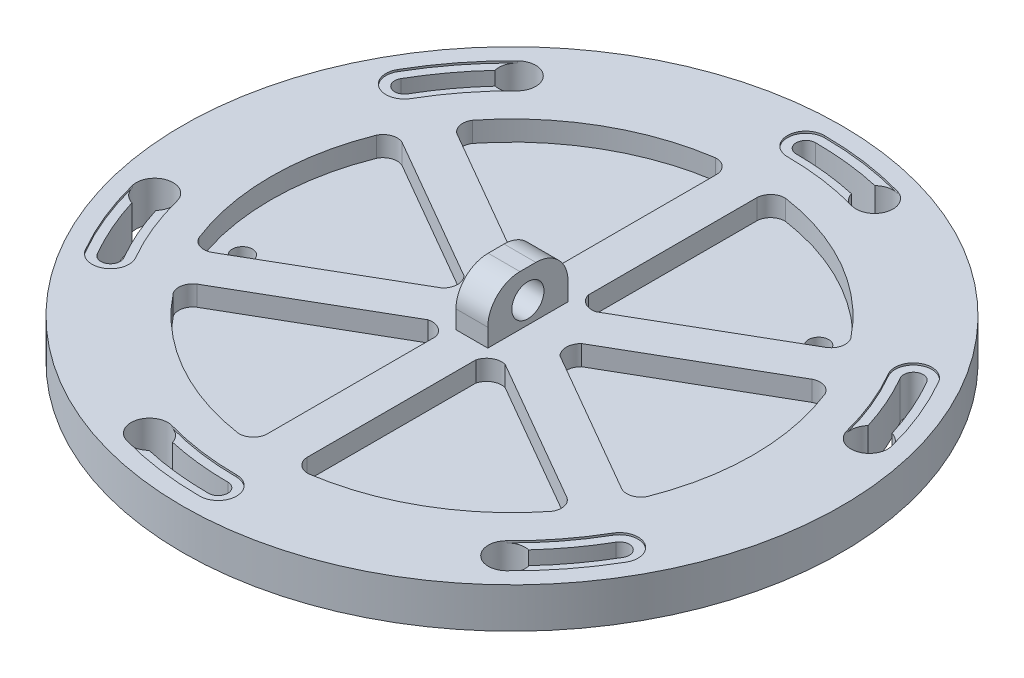
from build123d import *

# Parameters (mm, degrees)
SKETCH1_R           = 82
BOSS_EXTRUDE1_DEPTH = 10
BOSS_EXTRUDE3_DEPTH = 9.525
CIRPATTERN1_COUNT   = 6
CUT_EXTRUDE1_DEPTH  = 5
SKETCH3_R           = 2.5
CUT_EXTRUDE2_DEPTH  = 5
SKETCH3_3_R         = 2.5
CUT_EXTRUDE3_DEPTH  = 5
SKETCH5_W           = 7.911182114
SKETCH5_H           = 19.959178222
BOSS_EXTRUDE5_DEPTH = 12.5
FILLET2_R           = 8
SKETCH7_R           = 4
CUT_EXTRUDE4_DEPTH  = 8.5


with BuildPart() as part:
    # Sketch1 → Boss-Extrude1 (new body)
    with BuildSketch(Plane(origin=(0, 0, 0), x_dir=(1, 0, 0), z_dir=(0, 1, 0))):
        Circle(SKETCH1_R)
        with BuildLine():
            ThreePointArc((0, -68.539794907), (4.585205093, -73.125), (0, -77.710205093))
            ThreePointArc((0, -77.710205093), (-10.627709007, -76.980047914), (-21.05570427, -74.803297343))
            ThreePointArc((-21.05570427, -74.803297343), (-24.227021824, -69.147242492), (-18.570966974, -65.975924939))
            ThreePointArc((-18.570966974, -65.975924939), (-9.373556469, -67.895801969), (0, -68.539794907))
        make_face(mode=Mode.SUBTRACT)
        with BuildLine():
            ThreePointArc((-59.357203559, -34.269897453), (-61.035505105, -40.533404092), (-67.299011744, -38.855102547))
            ThreePointArc((-67.299011744, -38.855102547), (-71.980531582, -29.286157973), (-75.309407921, -19.166873879))
            ThreePointArc((-75.309407921, -19.166873879), (-71.996779512, -13.592404889), (-66.422310522, -16.905033297))
            ThreePointArc((-66.422310522, -16.905033297), (-63.48626755, -25.830162958), (-59.357203559, -34.269897453))
        make_face(mode=Mode.SUBTRACT)
        with BuildLine():
            ThreePointArc((59.357203559, -34.269897453), (65.620710198, -32.591595908), (67.299011744, -38.855102547))
            ThreePointArc((67.299011744, -38.855102547), (61.352822575, -47.693889942), (54.25370365, -55.636423464))
            ThreePointArc((54.25370365, -55.636423464), (47.769757688, -55.554837604), (47.851343548, -49.070891641))
            ThreePointArc((47.851343548, -49.070891641), (54.112711081, -42.065639011), (59.357203559, -34.269897453))
        make_face(mode=Mode.SUBTRACT)
        with BuildLine():
            ThreePointArc((-59.357203559, 34.269897453), (-65.620710198, 32.591595908), (-67.299011744, 38.855102547))
            ThreePointArc((-67.299011744, 38.855102547), (-61.352822575, 47.693889942), (-54.25370365, 55.636423464))
            ThreePointArc((-54.25370365, 55.636423464), (-47.769757688, 55.554837604), (-47.851343548, 49.070891641))
            ThreePointArc((-47.851343548, 49.070891641), (-54.112711081, 42.065639011), (-59.357203559, 34.269897453))
        make_face(mode=Mode.SUBTRACT)
        with BuildLine():
            ThreePointArc((59.357203559, 34.269897453), (61.035505105, 40.533404092), (67.299011744, 38.855102547))
            ThreePointArc((67.299011744, 38.855102547), (71.980531582, 29.286157973), (75.309407921, 19.166873879))
            ThreePointArc((75.309407921, 19.166873879), (71.996779512, 13.592404889), (66.422310522, 16.905033297))
            ThreePointArc((66.422310522, 16.905033297), (63.48626755, 25.830162958), (59.357203559, 34.269897453))
        make_face(mode=Mode.SUBTRACT)
        with BuildLine():
            ThreePointArc((0, 68.539794907), (-4.585205093, 73.125), (0, 77.710205093))
            ThreePointArc((0, 77.710205093), (10.627709007, 76.980047914), (21.05570427, 74.803297343))
            ThreePointArc((21.05570427, 74.803297343), (24.227021824, 69.147242492), (18.570966974, 65.975924939))
            ThreePointArc((18.570966974, 65.975924939), (9.373556469, 67.895801969), (0, 68.539794907))
        make_face(mode=Mode.SUBTRACT)
    extrude(amount=BOSS_EXTRUDE1_DEPTH)

    # Sketch1_4 → Boss-Extrude3 (add)
    with BuildSketch(Plane(origin=(0, 0, 0), x_dir=(1, 0, 0), z_dir=(0, 1, 0))):
        with BuildLine():
            ThreePointArc((-75.309407921, -19.166873879), (-71.980531582, -29.286157973), (-67.299011744, -38.855102547))
            ThreePointArc((-67.299011744, -38.855102547), (-61.035505105, -40.533404092), (-59.357203559, -34.269897453))
            ThreePointArc((-59.357203559, -34.269897453), (-63.48626755, -25.830162958), (-66.422310522, -16.905033297))
            ThreePointArc((-66.422310522, -16.905033297), (-66.418285743, -19.150940539), (-67.48132535, -21.129339471))
            ThreePointArc((-67.48132535, -21.129339471), (-64.751733563, -28.414631056), (-61.238335159, -35.355969289))
            ThreePointArc((-61.238335159, -35.355969289), (-62.121576941, -38.652272492), (-65.417880144, -37.769030711))
            ThreePointArc((-65.417880144, -37.769030711), (-69.197773577, -30.293016611), (-72.126599919, -22.444427093))
            ThreePointArc((-72.126599919, -22.444427093), (-74.155284422, -21.230290389), (-75.309407921, -19.166873879))
        make_face()
    boss_extrude3 = extrude(amount=BOSS_EXTRUDE3_DEPTH)

    # CirPattern1: Boss-Extrude3 ×6 about axis
    cirpattern1_axis = Axis((0, 10, 0), (0, 1, 0))
    for i in range(1, CIRPATTERN1_COUNT):
        add(boss_extrude3.rotate(cirpattern1_axis, i * 360 / CIRPATTERN1_COUNT))

    # Sketch2 → Cut-Extrude1 (cut)
    with BuildSketch(Plane(origin=(0, 10, 0), x_dir=(1, 0, 0), z_dir=(0, 1, 0))):
        with BuildLine():
            Line((-14.620190528, 2.667468245), (-51.015872171, 23.680524839))
            ThreePointArc((-51.015872171, 23.680524839), (-53.723615936, 23.879831653), (-55.779211114, 22.106098875))
            ThreePointArc((-55.779211114, 22.106098875), (-60, 0), (-55.779211114, -22.106098875))
            ThreePointArc((-55.779211114, -22.106098875), (-53.723615936, -23.879831653), (-51.015872171, -23.680524839))
            Line((-51.015872171, -23.680524839), (-14.620190528, -2.667468245))
            ThreePointArc((-14.620190528, -2.667468245), (-13.515289004, 0), (-14.620190528, 2.667468245))
        make_face()
        with BuildLine():
            Line((-5, 13.995190528), (-5, 56.021303716))
            ThreePointArc((-5, 56.021303716), (-6.181267118, 58.46593201), (-8.745162353, 59.359263266))
            ThreePointArc((-8.745162353, 59.359263266), (-30, 51.961524227), (-47.034048761, 37.253164391))
            ThreePointArc((-47.034048761, 37.253164391), (-47.542348818, 34.586100357), (-46.015872171, 32.340778877))
            Line((-46.015872171, 32.340778877), (-9.620190528, 11.327722283))
            ThreePointArc((-9.620190528, 11.327722283), (-6.757644502, 11.704583617), (-5, 13.995190528))
        make_face()
        with BuildLine():
            Line((-9.620190528, -11.327722283), (-46.015872171, -32.340778877))
            ThreePointArc((-46.015872171, -32.340778877), (-47.542348818, -34.586100357), (-47.034048761, -37.253164391))
            ThreePointArc((-47.034048761, -37.253164391), (-30, -51.961524227), (-8.745162353, -59.359263266))
            ThreePointArc((-8.745162353, -59.359263266), (-6.181267118, -58.46593201), (-5, -56.021303716))
            Line((-5, -56.021303716), (-5, -13.995190528))
            ThreePointArc((-5, -13.995190528), (-6.757644502, -11.704583617), (-9.620190528, -11.327722283))
        make_face()
        with BuildLine():
            Line((9.620190528, 11.327722283), (46.015872171, 32.340778877))
            ThreePointArc((46.015872171, 32.340778877), (47.542348818, 34.586100357), (47.034048761, 37.253164391))
            ThreePointArc((47.034048761, 37.253164391), (30, 51.961524227), (8.745162353, 59.359263266))
            ThreePointArc((8.745162353, 59.359263266), (6.181267118, 58.46593201), (5, 56.021303716))
            Line((5, 56.021303716), (5, 13.995190528))
            ThreePointArc((5, 13.995190528), (6.757644502, 11.704583617), (9.620190528, 11.327722283))
        make_face()
        with BuildLine():
            Line((14.620190528, -2.667468245), (51.015872171, -23.680524839))
            ThreePointArc((51.015872171, -23.680524839), (53.723615936, -23.879831653), (55.779211114, -22.106098875))
            ThreePointArc((55.779211114, -22.106098875), (60, 0), (55.779211114, 22.106098875))
            ThreePointArc((55.779211114, 22.106098875), (53.723615936, 23.879831653), (51.015872171, 23.680524839))
            Line((51.015872171, 23.680524839), (14.620190528, 2.667468245))
            ThreePointArc((14.620190528, 2.667468245), (13.515289004, 0), (14.620190528, -2.667468245))
        make_face()
        with BuildLine():
            Line((5, -13.995190528), (5, -56.021303716))
            ThreePointArc((5, -56.021303716), (6.181267118, -58.46593201), (8.745162353, -59.359263266))
            ThreePointArc((8.745162353, -59.359263266), (30, -51.961524227), (47.034048761, -37.253164391))
            ThreePointArc((47.034048761, -37.253164391), (47.542348818, -34.586100357), (46.015872171, -32.340778877))
            Line((46.015872171, -32.340778877), (9.620190528, -11.327722283))
            ThreePointArc((9.620190528, -11.327722283), (6.757644502, -11.704583617), (5, -13.995190528))
        make_face()
    extrude(amount=-CUT_EXTRUDE1_DEPTH, mode=Mode.SUBTRACT)

    # Sketch3 → Cut-Extrude2 (cut)
    with BuildSketch(Plane.XZ):
        with Locations((-51.685176347, 15.403969857)):
            Circle(SKETCH3_R)
    extrude(amount=-CUT_EXTRUDE2_DEPTH, mode=Mode.SUBTRACT)

    # Sketch3_3 → Cut-Extrude3 (cut)
    with BuildSketch(Plane.XZ):
        with Locations((39.514507533, -36.782411469)):
            Circle(SKETCH3_3_R)
    extrude(amount=-CUT_EXTRUDE3_DEPTH, mode=Mode.SUBTRACT)

    # Sketch5 → Boss-Extrude5 (add)
    with BuildSketch(Plane(origin=(0, 10, 0), x_dir=(1, 0, 0), z_dir=(0, 1, 0))):
        Rectangle(SKETCH5_W, SKETCH5_H)
    extrude(amount=BOSS_EXTRUDE5_DEPTH)

    # Fillet2
    fillet2_edges = [part.edges().sort_by_distance(p)[0] for p in [
        (0, 22.5, -9.979589111),
        (0, 22.5, 9.979589111),
    ]]
    fillet(fillet2_edges, radius=FILLET2_R)

    # Sketch7 → Cut-Extrude4 (cut)
    with BuildSketch(Plane.ZY.offset(3.955591057)):
        with Locations((0, 15.342929393)):
            Circle(SKETCH7_R)
    extrude(amount=-CUT_EXTRUDE4_DEPTH, mode=Mode.SUBTRACT)


solid = part.part
